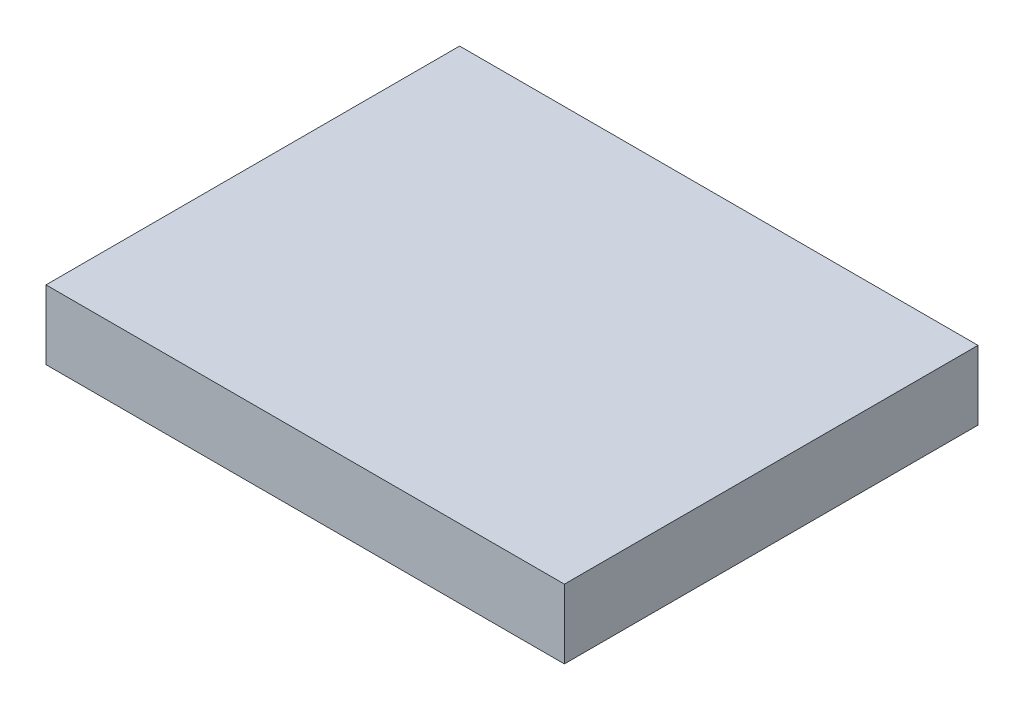
from build123d import *

# Parameters (mm, degrees)
SKETCH1_W           = 47.625
SKETCH1_H           = 38
BOSS_EXTRUDE1_DEPTH = 6.35


with BuildPart() as part:
    # Sketch1 → Boss-Extrude1 (new body)
    with BuildSketch(Plane(origin=(0, 0, 0), x_dir=(1, 0, 0), z_dir=(0, 1, 0))):
        with Locations((23.8125, 19)):
            Rectangle(SKETCH1_W, SKETCH1_H)
    extrude(amount=BOSS_EXTRUDE1_DEPTH)


solid = part.part
